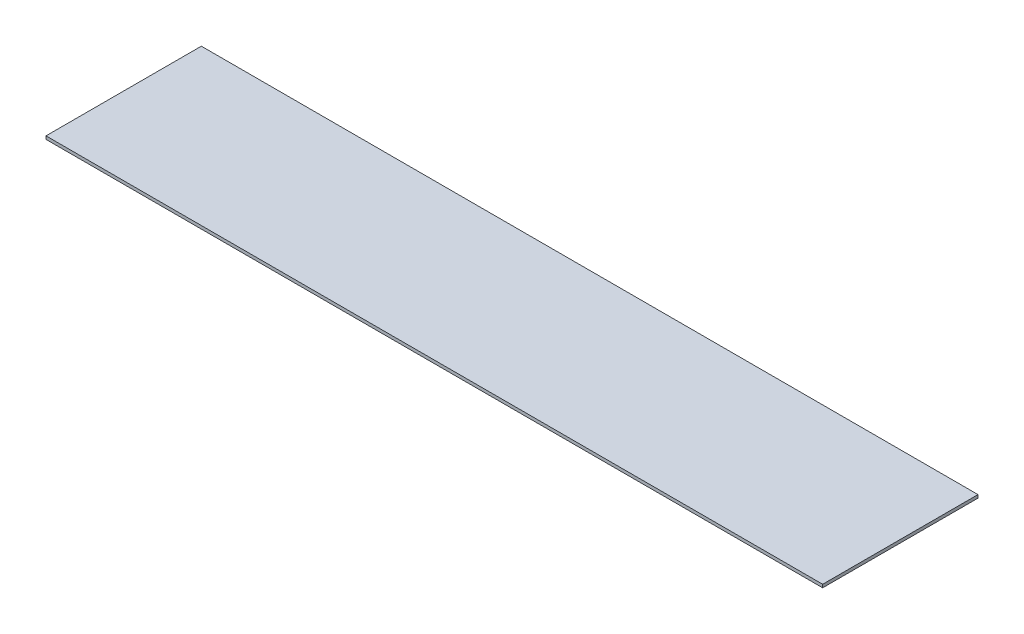
from build123d import *

# Parameters (mm, degrees)
SKETCH1_W           = 100
SKETCH1_H           = 20
BOSS_EXTRUDE1_DEPTH = 0.4


with BuildPart() as part:
    # Sketch1 → Boss-Extrude1 (new body)
    with BuildSketch(Plane(origin=(0, 0, 0), x_dir=(1, 0, 0), z_dir=(0, 1, 0))):
        Rectangle(SKETCH1_W, SKETCH1_H)
    extrude(amount=BOSS_EXTRUDE1_DEPTH)


solid = part.part
